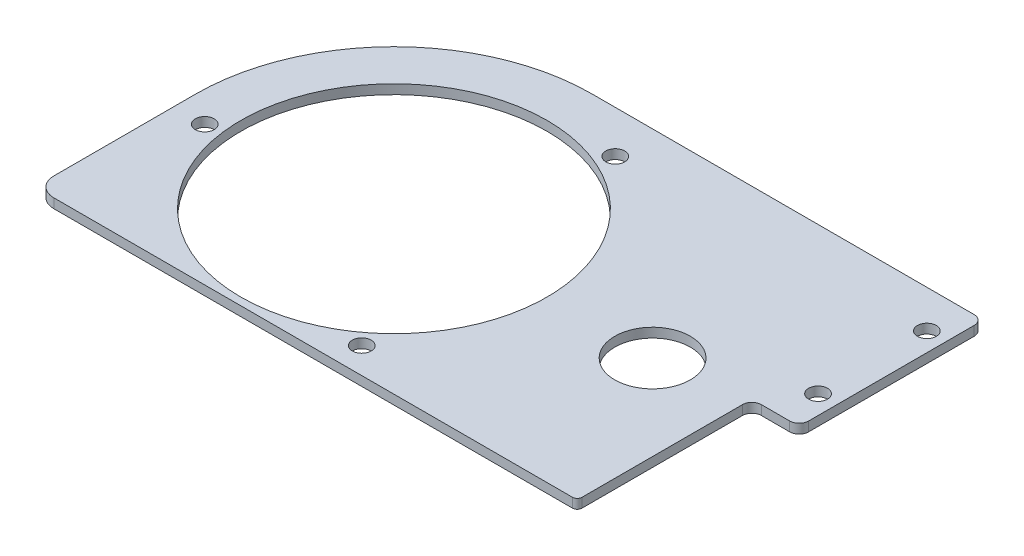
from build123d import *

# Parameters (mm, degrees)
SKETCH1_R           = 102.87
SKETCH1_R_2         = 6.35
BOSS_EXTRUDE1_DEPTH = 6.35
SKETCH6_R           = 25.4
CUT_EXTRUDE1_DEPTH  = 28.448


with BuildPart() as part:
    # Sketch1 → Boss-Extrude1 (new body)
    with BuildSketch(Plane(origin=(0, 0, 0), x_dir=(1, 0, 0), z_dir=(0, 1, 0))):
        with BuildLine():
            Line((256.521079071, 133.368920929), (0, 133.368920929))
            ThreePointArc((0, 133.368920929), (-94.306068389, 94.306068389), (-133.368920929, 0))
            Line((-133.368920929, 0), (-133.368920929, -95.231079071))
            ThreePointArc((-133.368920929, -95.231079071), (-129.64917705, -104.211335192), (-120.668920929, -107.931079071))
            Line((-120.668920929, -107.931079071), (227.955539535, -107.931079071))
            ThreePointArc((227.955539535, -107.931079071), (230.193914007, -107.003914007), (231.121079071, -104.765539535))
            Line((231.121079071, -104.765539535), (231.121079071, 3.100777109))
            ThreePointArc((231.121079071, 3.100777109), (232.98095101, 7.59090517), (237.471079071, 9.450777109))
            Line((237.471079071, 9.450777109), (256.521079071, 9.450777109))
            ThreePointArc((256.521079071, 9.450777109), (261.011207131, 11.310649048), (262.871079071, 15.800777109))
            Line((262.871079071, 15.800777109), (262.871079071, 127.018920929))
            ThreePointArc((262.871079071, 127.018920929), (261.011207131, 131.50904899), (256.521079071, 133.368920929))
        make_face()
        Circle(SKETCH1_R, mode=Mode.SUBTRACT)
        with Locations((-112.738641363, -14.374963544)):
            Circle(SKETCH1_R_2, mode=Mode.SUBTRACT)
        with Locations((43.920237074, 104.822009181)):
            Circle(SKETCH1_R_2, mode=Mode.SUBTRACT)
        with Locations((68.818404289, -90.447045637)):
            Circle(SKETCH1_R_2, mode=Mode.SUBTRACT)
        with Locations((250.171079071, 107.968920929)):
            Circle(SKETCH1_R_2, mode=Mode.SUBTRACT)
        with Locations((250.171079071, 34.850777109)):
            Circle(SKETCH1_R_2, mode=Mode.SUBTRACT)
    extrude(amount=BOSS_EXTRUDE1_DEPTH)

    # Sketch6 → Cut-Extrude1 (cut)
    with BuildSketch(Plane(origin=(0, 0, 0), x_dir=(1, 0, 0), z_dir=(0, 1, 0))):
        with Locations((173.810939206, 0)):
            Circle(SKETCH6_R)
    extrude(amount=CUT_EXTRUDE1_DEPTH, mode=Mode.SUBTRACT)


solid = part.part
